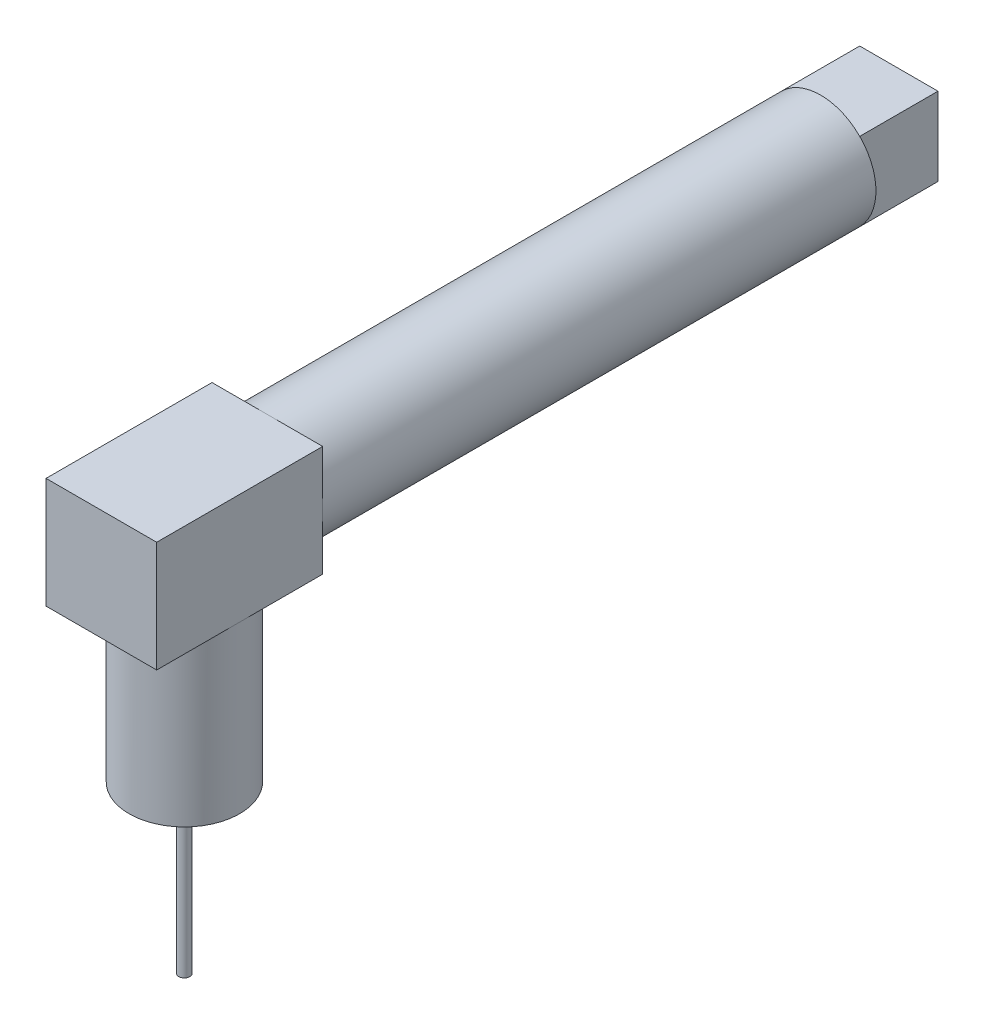
from build123d import *

# Parameters (mm, degrees)
CROQUIS2_R              = 5
SALIENTE_EXTRUIR1_DEPTH = 50
CROQUIS3_W              = 10
CROQUIS3_H              = 10
SALIENTE_EXTRUIR2_DEPTH = 15
CROQUIS5_R              = 5
SALIENTE_EXTRUIR3_DEPTH = 15
CROQUIS8_R              = 0.5
SALIENTE_EXTRUIR4_DEPTH = 15
CROQUIS11_W             = 7.071067812
CROQUIS11_H             = 7.071067812
SALIENTE_EXTRUIR5_DEPTH = 7.07


with BuildPart() as part:
    # Croquis2 → Saliente-Extruir1 (new body)
    with BuildSketch(Plane.XY):
        Circle(CROQUIS2_R)
    extrude(amount=SALIENTE_EXTRUIR1_DEPTH)

    # Croquis3 → Saliente-Extruir2 (add)
    with BuildSketch(Plane.XY.offset(50)):
        Rectangle(CROQUIS3_W, CROQUIS3_H)
    extrude(amount=SALIENTE_EXTRUIR2_DEPTH)

    # Croquis5 → Saliente-Extruir3 (add)
    with BuildSketch(Plane.XZ.offset(5)):
        with Locations(Location((0, 57.5, 0), (0, 0, 180))):  # turned: the seam where the file's is
            Circle(CROQUIS5_R)
    extrude(amount=SALIENTE_EXTRUIR3_DEPTH)

    # Croquis8 → Saliente-Extruir4 (add)
    with BuildSketch(Plane.XZ.offset(20)):
        with Locations(Location((0, 57.5, 0), (0, 0, 270))):  # turned: the seam where the file's is
            Circle(CROQUIS8_R)
    extrude(amount=SALIENTE_EXTRUIR4_DEPTH)

    # Croquis11 → Saliente-Extruir5 (add)
    with BuildSketch(Plane(origin=(0, 0, 0), x_dir=(-1, 0, 0), z_dir=(0, 0, -1))):
        Rectangle(CROQUIS11_W, CROQUIS11_H)
    extrude(amount=SALIENTE_EXTRUIR5_DEPTH)


solid = part.part
